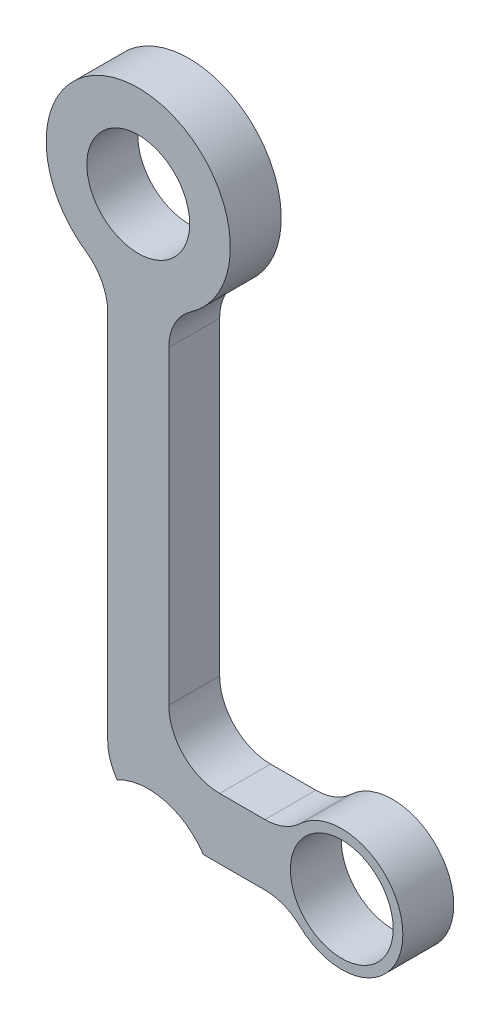
from build123d import *

# Parameters (mm, degrees)
ESQUISSE1_R             = 6.4135
BOSS_EXTRU_1_DEPTH      = 6.35
ESQUISSE5_R             = 8.255
ENL_V_MAT_EXTRU_3_DEPTH = 7.35


with BuildPart() as part:
    # Esquisse1 → Boss.-Extru.1 (new body)
    with BuildSketch(Plane.XY):
        with BuildLine():
            Line((-3.81, -14.6685), (-3.81, -60.96))
            ThreePointArc((-3.81, -60.96), (-1.950128061, -65.450128061), (2.54, -67.31))
            Line((2.54, -67.31), (15.811710267, -67.31))
            ThreePointArc((15.811710267, -67.31), (18.15660317, -67.758815604), (20.170023782, -69.041818182))
            ThreePointArc((20.170023782, -69.041818182), (33.02, -63.5), (20.170023782, -57.958181818))
            ThreePointArc((20.170023782, -57.958181818), (18.15660317, -59.241184396), (15.811710267, -59.69))
            Line((15.811710267, -59.69), (10.16, -59.69))
            ThreePointArc((10.16, -59.69), (5.669871939, -57.830128061), (3.81, -53.34))
            Line((3.81, -53.34), (3.81, -14.6685))
            ThreePointArc((3.81, -14.6685), (4.534969751, -11.722055584), (6.544341637, -9.448393238))
            ThreePointArc((6.544341637, -9.448393238), (0, 11.4935), (-6.544341637, -9.448393238))
            ThreePointArc((-6.544341637, -9.448393238), (-4.534969751, -11.722055584), (-3.81, -14.6685))
        make_face()
        Circle(ESQUISSE1_R, mode=Mode.SUBTRACT)
        with Locations((25.4, -63.5)):
            Circle(ESQUISSE1_R, mode=Mode.SUBTRACT)
    extrude(amount=BOSS_EXTRU_1_DEPTH)

    # Esquisse5 → Enlèv. mat.-Extru.3 (cut, through all)
    with BuildSketch(Plane(origin=(0, 0, 0), x_dir=(-1, 0, 0), z_dir=(0, 0, -1))):
        with Locations((-1.254065113, -71.897575416)):
            Circle(ESQUISSE5_R)
    extrude(amount=-ENL_V_MAT_EXTRU_3_DEPTH, mode=Mode.SUBTRACT)


solid = part.part
